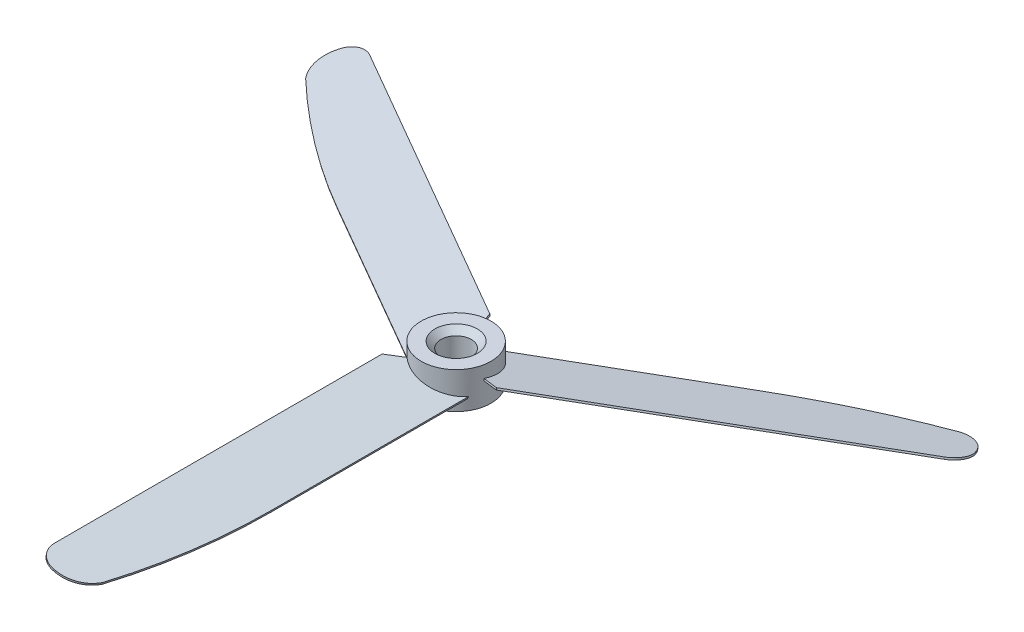
from build123d import *

# Parameters (mm, degrees)
SKETCH1_R           = 5.75
BOSS_EXTRUDE1_DEPTH = 3
BOSS_EXTRUDE2_DEPTH = 0.15
CIRPATTERN1_COUNT   = 3
SKETCH4_R           = 2.5
CUT_EXTRUDE1_DEPTH  = 7
CHAMFER1_SIZE       = 1


with BuildPart() as part:
    # Sketch1 → Boss-Extrude1 (new body, symmetric)
    with BuildSketch(Plane(origin=(0, 0, 0), x_dir=(1, 0, 0), z_dir=(0, 1, 0))):
        Circle(SKETCH1_R)
    extrude(amount=BOSS_EXTRUDE1_DEPTH, both=True)

    # Sketch3 → Boss-Extrude2 (add, symmetric)
    with BuildSketch(Plane(origin=(0, 0, 0), x_dir=(0.974370065, -0.224951054, 0), z_dir=(-0.224951054, -0.974370065, 0))):
        with BuildLine():
            Line((-3.401230627, 3.94493197), (-5.967495519, 6.417230684))
            Line((-5.967495519, 6.417230684), (-5.967495519, 60.5))
            ThreePointArc((-5.967495519, 60.5), (-5.088815862, 62.621320344), (-2.967495519, 63.5))
            Line((-2.967495519, 63.5), (-2.64407202, 63.5))
            ThreePointArc((-2.64407202, 63.5), (0.188980824, 62.61992859), (2.024718143, 60.289524634))
            ThreePointArc((2.024718143, 60.289524634), (4.284220879, 47.869969205), (5.041015214, 35.26925605))
            Line((5.041015214, 35.26925605), (5.041015214, 1.396310084))
            add(Edge.make_bspline(
                [(-3.401230627, 3.94493197), (1.650654294, 7.536977948), (5.041015214, 1.396310084)],
                knots=[0, 0, 0, 1, 1, 1], degree=2))
        make_face()
    boss_extrude2 = extrude(amount=BOSS_EXTRUDE2_DEPTH, both=True)

    # CirPattern1: Boss-Extrude2 ×3 about axis
    cirpattern1_axis = Axis((0, 0, 0), (0, 1, 0))
    for i in range(1, CIRPATTERN1_COUNT):
        add(boss_extrude2.rotate(cirpattern1_axis, i * 360 / CIRPATTERN1_COUNT))

    # Sketch4 → Cut-Extrude1 (cut, through all)
    with BuildSketch(Plane.XZ.offset(3)):
        Circle(SKETCH4_R)
    extrude(amount=-CUT_EXTRUDE1_DEPTH, mode=Mode.SUBTRACT)

    # Chamfer1
    chamfer1_edges = [part.edges().sort_by_distance(p)[0] for p in [
        (-2.5, 3, 0),
        (-2.5, -3, 0),
    ]]
    chamfer(chamfer1_edges, length=CHAMFER1_SIZE)


solid = part.part
